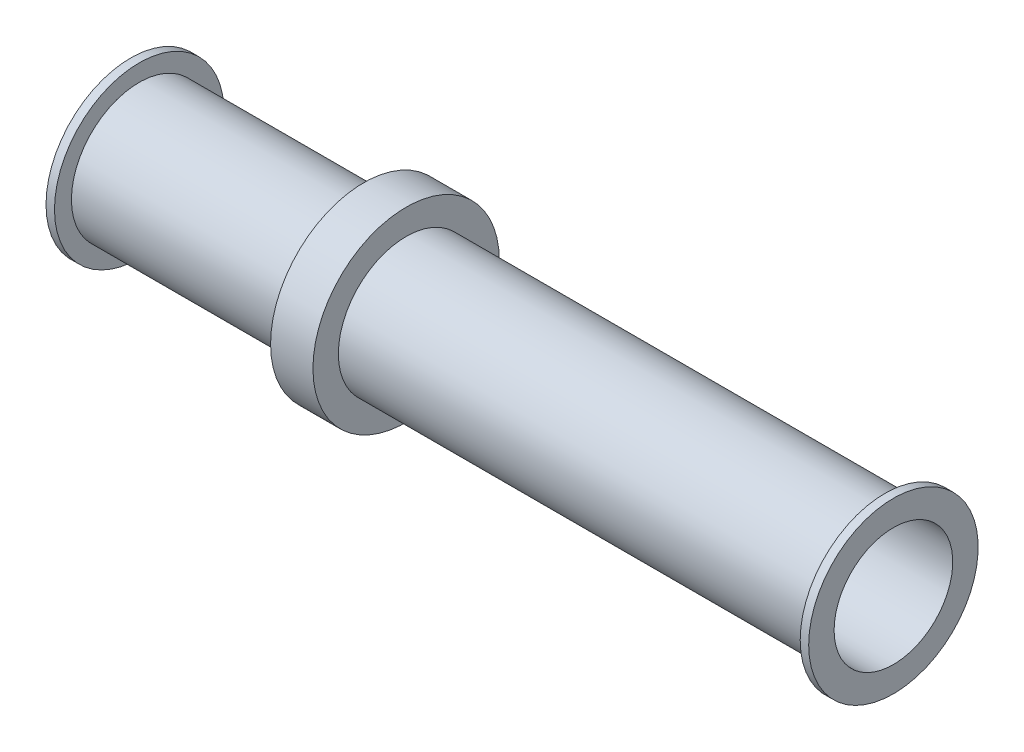
from build123d import *


with BuildPart() as part:
    # Sketch1 → Revolve1 (revolve)
    with BuildSketch(Plane.XY):
        Polygon((0, 1.778), (0, 2.54), (0.254, 2.54), (0.254, 2.032), (6.985, 2.032), (6.985, 2.794), (8.255, 2.794), (8.255, 2.032), (22.606, 2.032), (22.606, 2.54), (22.86, 2.54), (22.86, 1.778), align=None)
    revolve(axis=Axis((0, 0, 0), (1, 0, 0)))


solid = part.part
